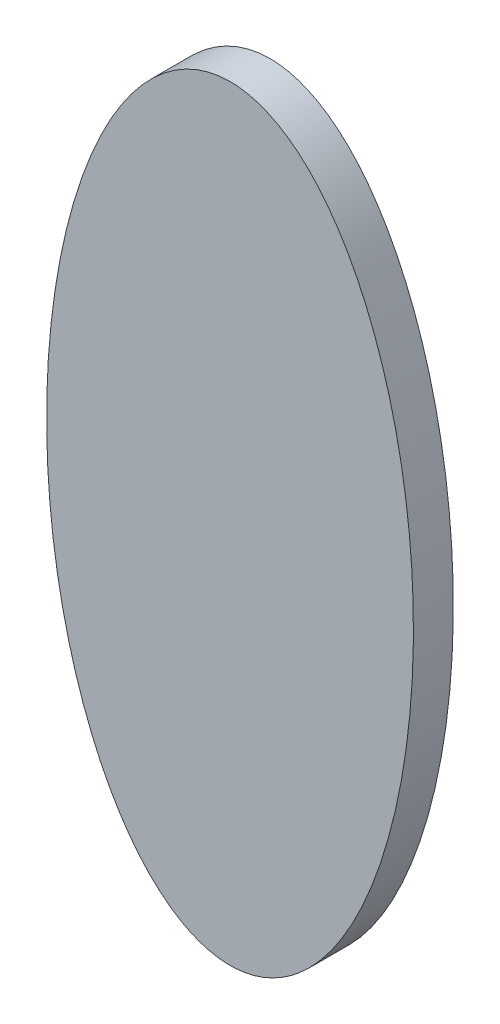
from build123d import *

# Parameters (mm, degrees)
SKETCH_1_RX     = 96
SKETCH_1_RY     = 46
EXTRUDE_1_DEPTH = 10


with BuildPart() as part:
    # Эскиз1 → Бобышка-Вытянуть1 (new body)
    with BuildSketch(Plane.XY):
        with Locations(Location((0, 0), (0, 0, 90))):
            Ellipse(SKETCH_1_RX, SKETCH_1_RY)
    extrude(amount=EXTRUDE_1_DEPTH)


solid = part.part
